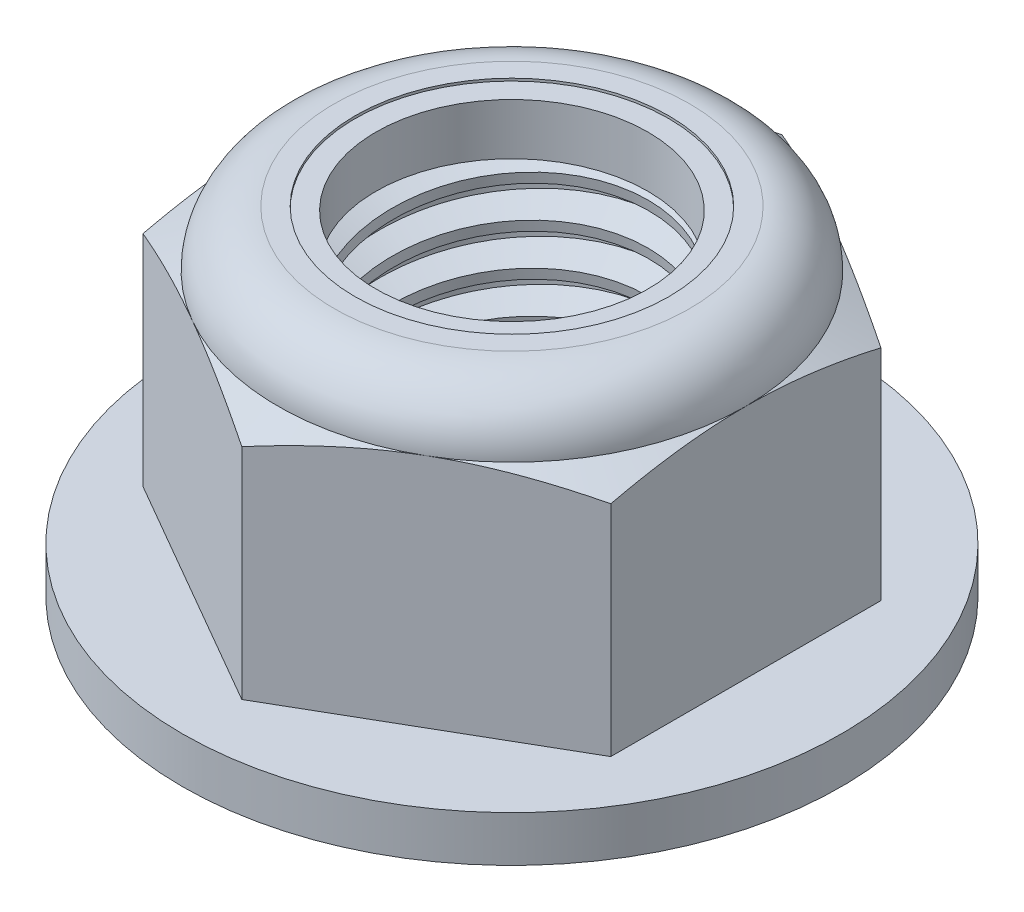
from build123d import *

# Parameters (mm, degrees)
EXTRUDE1_DEPTH      = 20.6375
SKETCH8_W           = 20.1295
SKETCH8_H           = 2.794
SKETCH2_W           = 9.525
SKETCH2_H           = 20.6375
LPATTERN1_COUNT     = 8
LPATTERN1_PITCH     = 2.54
LPATTERN1_COL_COUNT = 2
LPATTERN1_COL_PITCH = 2.54


with BuildPart() as part:
    # Sketch1 → Extrude1 (new body)
    with BuildSketch(Plane(origin=(0, 0, 0), x_dir=(1, 0, 0), z_dir=(0, 1, 0))):
        Polygon((0, 16.497783942), (-14.2875, 8.248891971), (-14.2875, -8.248891971), (0, -16.497783942), (14.2875, -8.248891971), (14.2875, 8.248891971), align=None)
    extrude(amount=EXTRUDE1_DEPTH)

    # Sketch8 → Revolve3 (revolve)
    with BuildSketch(Plane(origin=(0, 0, 0), x_dir=(0, 0, -1), z_dir=(1, 0, 0))):
        with Locations((10.06475, 1.397)):
            Rectangle(SKETCH8_W, SKETCH8_H)
    revolve(axis=Axis((0, 0, 0), (0, -1, 0)))

    # Sketch4 → Cut-Revolve2 (revolve, cut)
    with BuildSketch(Plane(origin=(0, 0, 0), x_dir=(0, 0, -1), z_dir=(1, 0, 0))):
        Polygon((0, 20.6375), (9.525, 20.6375), (8.309111622, 20.070521938), (8.309111622, 0.566978062), (9.525, 0), (0, 0), align=None)
    revolve(axis=Axis((0, 20.6375, 0), (0, 1, 0)), mode=Mode.SUBTRACT)


with BuildPart() as body_2:
    # Sketch2 → Revolve1 (revolve)
    with BuildSketch(Plane(origin=(0, 0, 0), x_dir=(0, 0, -1), z_dir=(1, 0, 0))):
        with Locations((4.7625, 10.31875)):
            Rectangle(SKETCH2_W, SKETCH2_H)
    revolve(axis=Axis((0, -9.525, 0), (0, 1, 0)))

    # Sketch3 → Cut-Revolve1 (revolve, cut)
    with BuildSketch(Plane(origin=(0, 0, 0), x_dir=(0, 0, -1), z_dir=(1, 0, 0))):
        Polygon((9.566961981, 20.322785142), (9.860695849, 18.119781132), (8.393035584, 18.72486757), (8.309111622, 19.354297287), align=None)
    cut_revolve1 = revolve(axis=Axis((0, 20.6375, 0.361519207), (0, -0.991227901, -0.13216372)), mode=Mode.SUBTRACT)

    # LPattern1: Cut-Revolve1 ×8
    with Locations(*[(0, -i * LPATTERN1_PITCH, 0) for i in range(1, LPATTERN1_COUNT)]):
        add(cut_revolve1, mode=Mode.SUBTRACT)

    # LPattern1 col: Cut-Revolve1 ×2
    with Locations(*[(0, i * LPATTERN1_COL_PITCH, 0) for i in range(1, LPATTERN1_COL_COUNT)]):
        add(cut_revolve1, mode=Mode.SUBTRACT)


with BuildPart() as part_1:
    add(part.part)

    # Combine1: cut body 2
    add(body_2.part, mode=Mode.SUBTRACT)

    # Sketch5 → Cut-Revolve3 (revolve, cut)
    with BuildSketch(Plane(origin=(0, 0, 0), x_dir=(0, 0, -1), z_dir=(1, 0, 0))):
        with BuildLine():
            Line((16.497783942, 2.794), (16.497783942, 16.167244338))
            Line((16.497783942, 16.167244338), (14.2875, 17.197916667))
            ThreePointArc((14.2875, 17.197916667), (13.280069366, 19.630069366), (10.847916667, 20.6375))
            Line((10.847916667, 20.6375), (10.847916667, 21.9075))
            Line((10.847916667, 21.9075), (17.767783942, 21.9075))
            Line((17.767783942, 21.9075), (17.767783942, 2.794))
            Line((17.767783942, 2.794), (16.497783942, 2.794))
        make_face()
    revolve(axis=Axis((0, 0, 0), (0, 1, 0)), mode=Mode.SUBTRACT)

    # Sketch6 → Cut-Revolve4 (revolve, cut)
    with BuildSketch(Plane(origin=(0, 0, 0), x_dir=(0, 0, -1), z_dir=(1, 0, 0))):
        with BuildLine():
            Line((0, 17.197916667), (14.1351, 17.197916667))
            ThreePointArc((14.1351, 17.197916667), (13.172306293, 19.522306293), (10.847916667, 20.4851))
            Line((10.847916667, 20.4851), (9.578514144, 20.4851))
            Line((9.578514144, 20.4851), (9.578514144, 21.9075))
            Line((9.578514144, 21.9075), (0, 21.9075))
            Line((0, 21.9075), (0, 17.197916667))
        make_face()
    revolve(axis=Axis((0, 21.9075, 0), (0, 1, 0)), mode=Mode.SUBTRACT)


with BuildPart() as body_2_2:
    # Sketch7 → Revolve2 (revolve)
    with BuildSketch(Plane(origin=(0, 0, 0), x_dir=(0, 0, -1), z_dir=(1, 0, 0))):
        with BuildLine():
            Line((8.309111622, 17.274116667), (14.05799572, 17.274116667))
            ThreePointArc((14.05799572, 17.274116667), (13.091322229, 19.49520756), (10.847916667, 20.4089))
            Line((10.847916667, 20.4089), (8.309111622, 20.4089))
            Line((8.309111622, 20.4089), (8.309111622, 17.274116667))
        make_face()
    revolve(axis=Axis((0, 17.274116667, 0), (0, 1, 0)))


solid = Compound([part_1.part, body_2_2.part])
